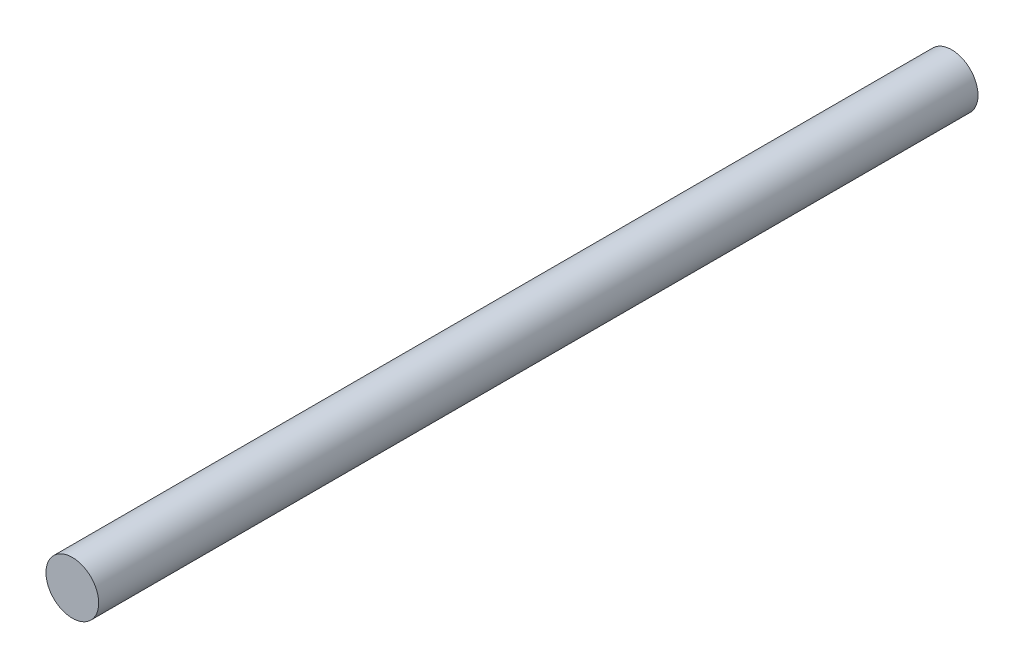
from build123d import *

# Parameters (mm, degrees)
SCHIZZO1_R                   = 3
ESTRUSIONE_ESTRUSIONE1_DEPTH = 100


with BuildPart() as part:
    # Schizzo1 → Estrusione-Estrusione1 (new body)
    with BuildSketch(Plane.XY):
        with Locations((115, -2)):
            Circle(SCHIZZO1_R)
    extrude(amount=-ESTRUSIONE_ESTRUSIONE1_DEPTH)


solid = part.part
